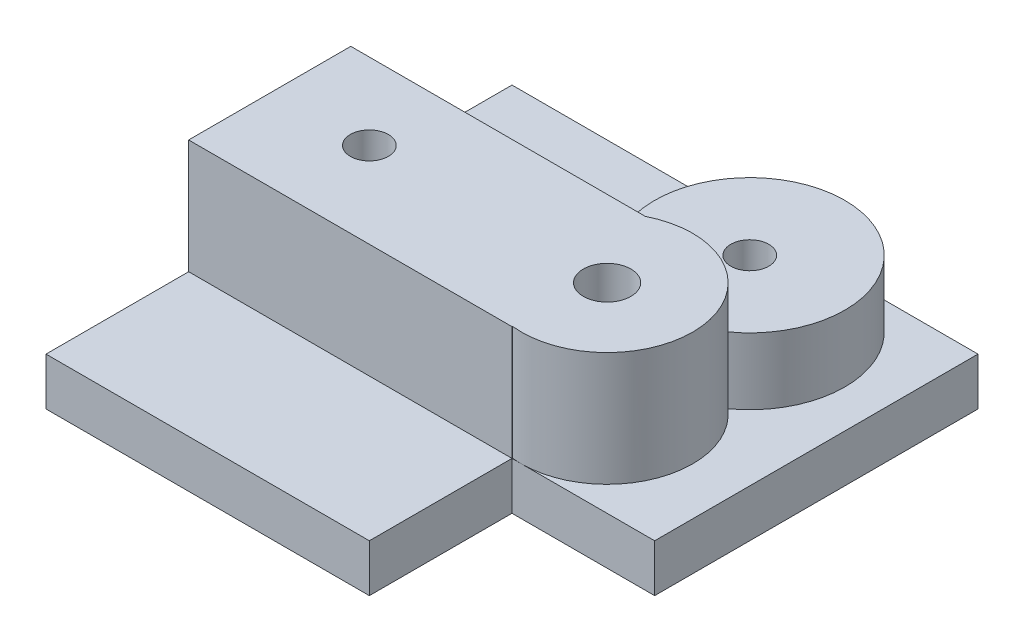
from build123d import *

# Parameters (mm, degrees)
SKETCH1_R           = 2
SKETCH1_R_2         = 2.5
BOSS_EXTRUDE1_DEPTH = 5
SKETCH2_R           = 4
CUT_EXTRUDE1_DEPTH  = 2
SKETCH3_R           = 10
BOSS_EXTRUDE2_DEPTH = 12
SKETCH4_R           = 2
CUT_EXTRUDE2_DEPTH  = 12
SKETCH5_R           = 10
SKETCH5_R_2         = 2
CUT_EXTRUDE3_DEPTH  = 5
SKETCH6_R           = 9
SKETCH6_R_2         = 2.5
BOSS_EXTRUDE3_DEPTH = 12
SKETCH7_R           = 2.299679875
SKETCH7_W           = 34
SKETCH7_H           = 17.049766734
SKETCH7_R_2         = 2
BOSS_EXTRUDE4_DEPTH = 12
SKETCH9_R           = 2.5
CUT_EXTRUDE5_DEPTH  = 27


with BuildPart() as part:
    # Sketch1 → Boss-Extrude1 (new body)
    with BuildSketch(Plane(origin=(0, 0, 0), x_dir=(1, 0, 0), z_dir=(0, 1, 0))):
        Polygon((0, 49), (0, 0), (34, 0), (34, 15), (49, 15), (49, 49), align=None)
        with Locations((10, 24)):
            Circle(SKETCH1_R, mode=Mode.SUBTRACT)
        with Locations((35, 24)):
            Circle(SKETCH1_R_2, mode=Mode.SUBTRACT)
        with Locations((10, 39)):
            Circle(SKETCH1_R, mode=Mode.SUBTRACT)
        with Locations((35, 39)):
            Circle(SKETCH1_R, mode=Mode.SUBTRACT)
    extrude(amount=BOSS_EXTRUDE1_DEPTH)

    # Sketch2 → Cut-Extrude1 (cut)
    with BuildSketch(Plane(origin=(0, 5, 0), x_dir=(1, 0, 0), z_dir=(0, 1, 0))):
        with Locations((10, 39)):
            Circle(SKETCH2_R)
    extrude(amount=-CUT_EXTRUDE1_DEPTH, mode=Mode.SUBTRACT)

    # Sketch3 → Boss-Extrude2 (add)
    with BuildSketch(Plane(origin=(0, 5, 0), x_dir=(1, 0, 0), z_dir=(0, 1, 0))):
        with Locations((35, 39)):
            Circle(SKETCH3_R)
    extrude(amount=BOSS_EXTRUDE2_DEPTH)

    # Sketch4 → Cut-Extrude2 (cut)
    with BuildSketch(Plane.XZ.offset(-5)):
        with Locations((35, -39)):
            Circle(SKETCH4_R)
    extrude(amount=-CUT_EXTRUDE2_DEPTH, mode=Mode.SUBTRACT)

    # Sketch5 → Cut-Extrude3 (cut)
    with BuildSketch(Plane(origin=(0, 17, 0), x_dir=(1, 0, 0), z_dir=(0, 1, 0))):
        with Locations((35, 39)):
            Circle(SKETCH5_R)
        with Locations((35, 39)):
            Circle(SKETCH5_R_2, mode=Mode.SUBTRACT)
    extrude(amount=-CUT_EXTRUDE3_DEPTH, mode=Mode.SUBTRACT)

    # Sketch6 → Boss-Extrude3 (add)
    with BuildSketch(Plane(origin=(0, 5, 0), x_dir=(1, 0, 0), z_dir=(0, 1, 0))):
        with Locations((35, 24)):
            Circle(SKETCH6_R)
        with Locations((35, 24)):
            Circle(SKETCH6_R_2, mode=Mode.SUBTRACT)
    extrude(amount=BOSS_EXTRUDE3_DEPTH)

    # Sketch7 → Boss-Extrude4 (add)
    with BuildSketch(Plane(origin=(0, 5, 0), x_dir=(1, 0, 0), z_dir=(0, 1, 0))):
        with Locations((35, 24)):
            Circle(SKETCH7_R)
        with Locations((17, 23.524883367)):
            Rectangle(SKETCH7_W, SKETCH7_H)
        with Locations((10, 24)):
            Circle(SKETCH7_R_2, mode=Mode.SUBTRACT)
    extrude(amount=BOSS_EXTRUDE4_DEPTH)

    # Sketch9 → Cut-Extrude5 (cut)
    with BuildSketch(Plane(origin=(0, 17, 0), x_dir=(1, 0, 0), z_dir=(0, 1, 0))):
        with Locations((35, 24)):
            Circle(SKETCH9_R)
    extrude(amount=-CUT_EXTRUDE5_DEPTH, mode=Mode.SUBTRACT)


solid = part.part
